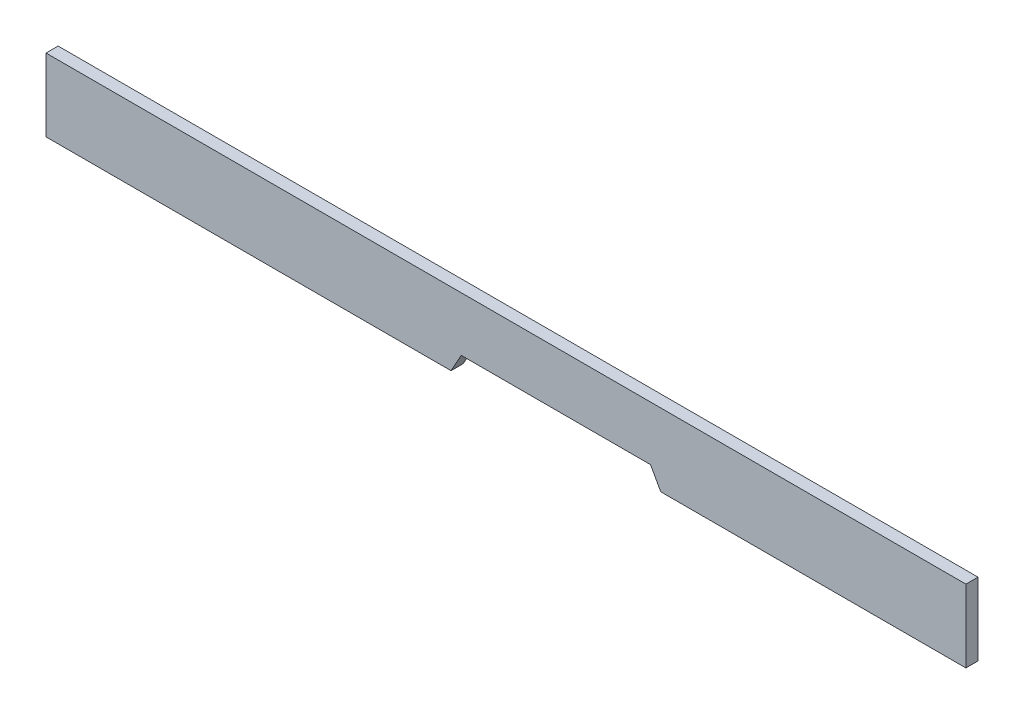
from build123d import *

# Parameters (mm, degrees)
SKETCH1_W           = 120.65
SKETCH1_H           = 9.525
BOSS_EXTRUDE1_DEPTH = 0.79375
CUT_EXTRUDE1_DEPTH  = 2.5875


with BuildPart() as part:
    # Sketch1 → Boss-Extrude1 (new body, symmetric)
    with BuildSketch(Plane.XY):
        Rectangle(SKETCH1_W, SKETCH1_H)
    extrude(amount=BOSS_EXTRUDE1_DEPTH, both=True)

    # Sketch2 → Cut-Extrude1 (cut, through all)
    with BuildSketch(Plane.XY.offset(0.79375)):
        Polygon((-7.202243564, -4.7625), (-5.855664106, -2.3495), (18.960360816, -2.3495), (20.306940273, -4.7625), align=None)
    extrude(amount=-CUT_EXTRUDE1_DEPTH, mode=Mode.SUBTRACT)


solid = part.part
